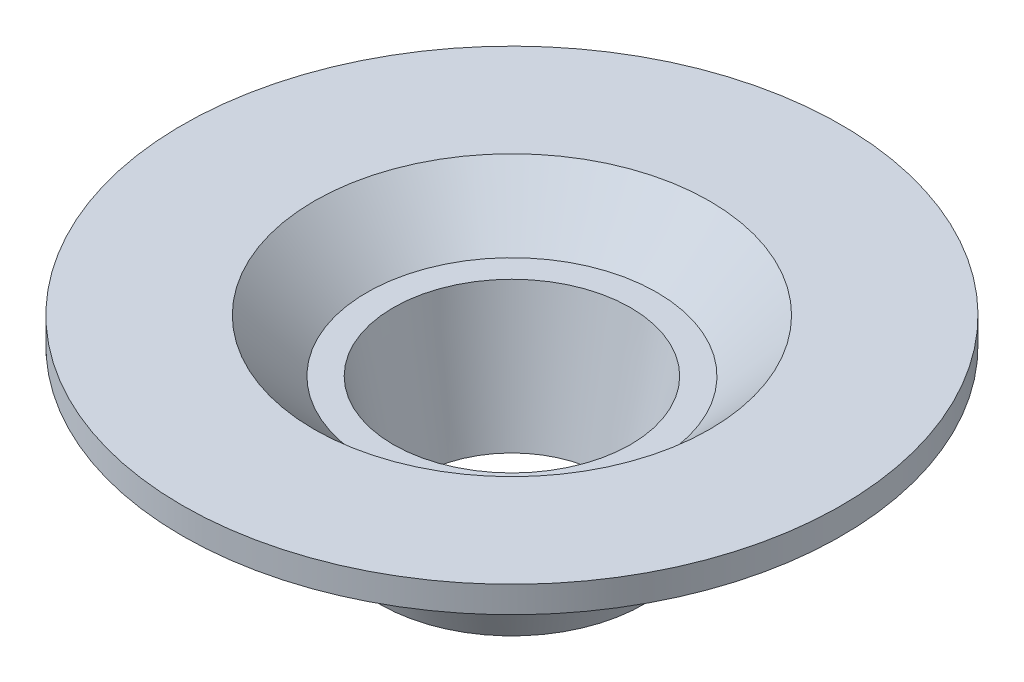
from build123d import *


with BuildPart() as part:
    # Sketch1 → Revolve1 (revolve)
    with BuildSketch(Plane(origin=(0, 0, 0), x_dir=(0, 0, -1), z_dir=(1, 0, 0))):
        Polygon((3.5, -8.134956375), (4.5, -3.134956375), (5.5, -3.134956375), (7.5, -1.134956375), (12.5, -1.134956375), (12.5, -2.134956375), (10.5, -2.134956375), (8.5, -4.134956375), (6.5, -4.134956375), (5, -8.134956375), align=None)
    revolve(axis=Axis((0, 0, 0), (0, -1, 0)))


solid = part.part
